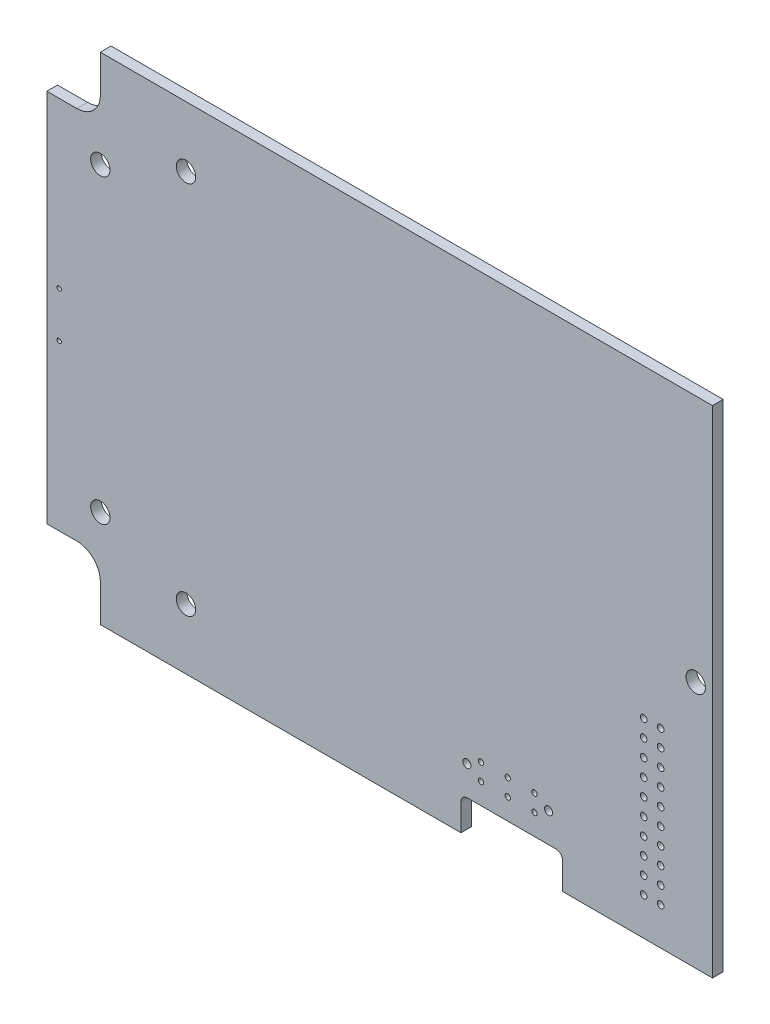
from build123d import *

# Parameters (mm, degrees)
BOSS_EXTRUDE1_DEPTH    = 1.6
M2_5_CLEARANCE_HOLE1_D = 2.9
SKETCH5_W              = 47.55
SKETCH5_H              = 74.1
CUT_EXTRUDE1_DEPTH     = 2.6
SKETCH6_R              = 0.325
CUT_EXTRUDE2_DEPTH     = 2.6
CUT_EXTRUDE3_DEPTH     = 2.6
SKETCH9_R              = 0.6
SKETCH9_R_2            = 0.4
CUT_EXTRUDE4_DEPTH     = 2.6
SKETCH10_R             = 0.5
CUT_EXTRUDE5_DEPTH     = 2.6


with BuildPart() as part:
    # Sketch2 → Boss-Extrude1 (new body)
    with BuildSketch(Plane.XY):
        with BuildLine():
            Line((371.950402667, 62.730474091), (253.950402667, 62.730474091))
            Line((253.950402667, 62.730474091), (253.950402667, 57.180474091))
            ThreePointArc((253.950402667, 57.180474091), (252.925276401, 54.705600357), (250.450402667, 53.680474091))
            Line((250.450402667, 53.680474091), (245.950402667, 53.680474091))
            Line((245.950402667, 53.680474091), (245.950402667, -2.319525909))
            Line((245.950402667, -2.319525909), (250.450402667, -2.319525909))
            ThreePointArc((250.450402667, -2.319525909), (252.925276401, -3.344652175), (253.950402667, -5.819525909))
            Line((253.950402667, -5.819525909), (253.950402667, -11.369525909))
            Line((253.950402667, -11.369525909), (371.950402667, -11.369525909))
            Line((371.950402667, -11.369525909), (371.950402667, -5.819525909))
            ThreePointArc((371.950402667, -5.819525909), (375.450402667, -2.319525909), (378.950402667, -5.819525909))
            Line((378.950402667, -5.819525909), (378.950402667, -11.369525909))
            Line((378.950402667, -11.369525909), (393.000402667, -11.369525909))
            Line((393.000402667, -11.369525909), (393.000402667, 62.730474091))
            Line((393.000402667, 62.730474091), (378.950402667, 62.730474091))
            Line((378.950402667, 62.730474091), (378.950402667, 57.180474091))
            ThreePointArc((378.950402667, 57.180474091), (375.450402667, 53.680474091), (371.950402667, 57.180474091))
            Line((371.950402667, 57.180474091), (371.950402667, 62.730474091))
        make_face()
    extrude(amount=BOSS_EXTRUDE1_DEPTH)

    # M2.5 Clearance Hole1 (through all)
    with Locations(Plane.XY.offset(1.6)):
        with Locations((347.250402667, -2.319525909), (342.950402667, 25.680474091), (347.250402667, 53.680474091), (266.750402667, -2.319525909), (253.950402667, 3.180474091), (266.750402667, 53.680474091), (253.950402667, 48.180474091)):
            Hole(M2_5_CLEARANCE_HOLE1_D / 2)

    # Sketch5 → Cut-Extrude1 (cut, through all)
    with BuildSketch(Plane.XY.offset(1.6)):
        with Locations((369.225402667, 25.680474091)):
            Rectangle(SKETCH5_W, SKETCH5_H)
    extrude(amount=-CUT_EXTRUDE1_DEPTH, mode=Mode.SUBTRACT)

    # Sketch6 → Cut-Extrude2 (cut, through all)
    with BuildSketch(Plane(origin=(0, 0, 0), x_dir=(-1, 0, 0), z_dir=(0, 0, -1))):
        with Locations((-247.800502667, 29.080474091)):
            Circle(SKETCH6_R)
        with Locations((-247.800502667, 22.280474091)):
            Circle(SKETCH6_R)
    extrude(amount=-CUT_EXTRUDE2_DEPTH, mode=Mode.SUBTRACT)

    # Sketch7 → Cut-Extrude3 (cut, through all)
    with BuildSketch(Plane(origin=(0, 0, 0), x_dir=(-1, 0, 0), z_dir=(0, 0, -1))):
        with BuildLine():
            Line((-307.850402667, -7.369525909), (-307.850402667, -12.319525909))
            Line((-307.850402667, -12.319525909), (-323.050402667, -12.319525909))
            Line((-323.050402667, -12.319525909), (-323.050402667, -7.369525909))
            ThreePointArc((-323.050402667, -7.369525909), (-322.757509449, -6.662419128), (-322.050402667, -6.369525909))
            Line((-322.050402667, -6.369525909), (-308.850402667, -6.369525909))
            ThreePointArc((-308.850402667, -6.369525909), (-308.143295886, -6.662419128), (-307.850402667, -7.369525909))
        make_face()
    extrude(amount=-CUT_EXTRUDE3_DEPTH, mode=Mode.SUBTRACT)

    # Sketch9 → Cut-Extrude4 (cut, through all)
    with BuildSketch(Plane(origin=(0, 0, 0), x_dir=(-1, 0, 0), z_dir=(0, 0, -1))):
        with Locations((-308.750402667, -1.969525909)):
            Circle(SKETCH9_R)
        with Locations((-310.850402667, -3.219525909)):
            Circle(SKETCH9_R_2)
        with Locations((-314.850402667, -3.219525909)):
            Circle(SKETCH9_R_2)
        with Locations((-314.850402667, -0.719525909)):
            Circle(SKETCH9_R_2)
        with Locations((-318.850402667, -0.719525909)):
            Circle(SKETCH9_R_2)
        with Locations((-318.850402667, -3.219525909)):
            Circle(SKETCH9_R_2)
        with Locations((-320.950402667, -1.969525909)):
            Circle(SKETCH9_R)
        with Locations((-310.850402667, -0.719525909)):
            Circle(SKETCH9_R_2)
    extrude(amount=-CUT_EXTRUDE4_DEPTH, mode=Mode.SUBTRACT)

    # Sketch10 → Cut-Extrude5 (cut, through all)
    with BuildSketch(Plane.XY.offset(1.6)):
        with Locations((335.163848042, -5.759525909)):
            Circle(SKETCH10_R)
        with Locations((337.703848042, -5.759525909)):
            Circle(SKETCH10_R)
        with Locations((337.703848042, -3.219525909)):
            Circle(SKETCH10_R)
        with Locations((335.163848042, -3.219525909)):
            Circle(SKETCH10_R)
        with Locations((335.163848042, -0.679525909)):
            Circle(SKETCH10_R)
        with Locations((337.703848042, -0.679525909)):
            Circle(SKETCH10_R)
        with Locations((335.163848042, 1.860474091)):
            Circle(SKETCH10_R)
        with Locations((337.703848042, 1.860474091)):
            Circle(SKETCH10_R)
        with Locations((335.163848042, 4.400474091)):
            Circle(SKETCH10_R)
        with Locations((337.703848042, 4.400474091)):
            Circle(SKETCH10_R)
        with Locations((335.163848042, 6.940474091)):
            Circle(SKETCH10_R)
        with Locations((337.703848042, 6.940474091)):
            Circle(SKETCH10_R)
        with Locations((335.163848042, 9.480474091)):
            Circle(SKETCH10_R)
        with Locations((337.703848042, 9.480474091)):
            Circle(SKETCH10_R)
        with Locations((335.163848042, 12.020474091)):
            Circle(SKETCH10_R)
        with Locations((337.703848042, 12.020474091)):
            Circle(SKETCH10_R)
        with Locations((335.163848042, 14.560474091)):
            Circle(SKETCH10_R)
        with Locations((337.703848042, 14.560474091)):
            Circle(SKETCH10_R)
        with Locations((335.163848042, 17.100474091)):
            Circle(SKETCH10_R)
        with Locations((337.703848042, 17.100474091)):
            Circle(SKETCH10_R)
    extrude(amount=-CUT_EXTRUDE5_DEPTH, mode=Mode.SUBTRACT)


solid = part.part
